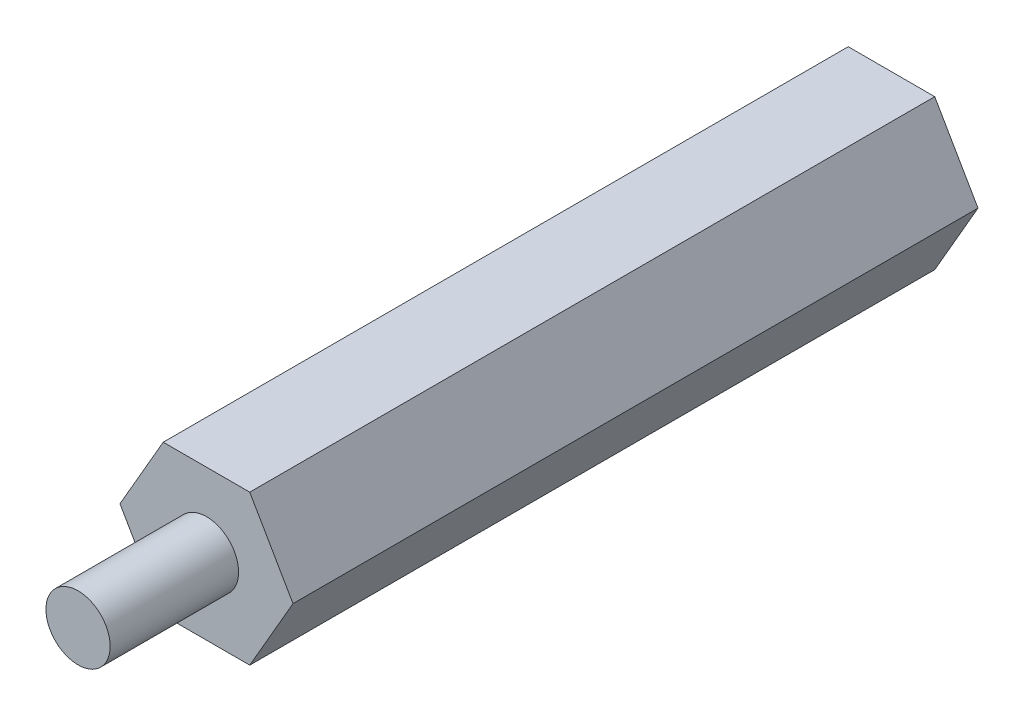
from build123d import *

# Parameters (mm, degrees)
EXTRUDE_1_DEPTH        = 32
SKETCH_2_R             = 1.5
EXTRUDE_2_DEPTH        = 6
HOLE_WIZARD_M3_1_D     = 2.5
HOLE_WIZARD_M3_1_DEPTH = 3.9
HOLE_WIZARD_M3_1_TIP   = 0.751075774


with BuildPart() as part:
    # 草图1 → 凸台-拉伸1 (new body)
    with BuildSketch(Plane.XY):
        Polygon((4.041451884, 0), (2.020725942, 3.5), (-2.020725942, 3.5), (-4.041451884, 0), (-2.020725942, -3.5), (2.020725942, -3.5), align=None)
    extrude(amount=EXTRUDE_1_DEPTH)

    # 草图2 → 凸台-拉伸2 (add)
    with BuildSketch(Plane.XY.offset(32)):
        Circle(SKETCH_2_R)
    extrude(amount=EXTRUDE_2_DEPTH)

    # M3 螺纹孔1
    with Locations(Plane(origin=(0, 0, 0), x_dir=(-1, 0, 0), z_dir=(0, 0, -1))):
        with Locations((0, 0)):
            Hole(HOLE_WIZARD_M3_1_D / 2, depth=HOLE_WIZARD_M3_1_DEPTH)
            with Locations((0, 0, -(HOLE_WIZARD_M3_1_DEPTH + HOLE_WIZARD_M3_1_TIP / 2))):  # 118° drill point
                Cone(0, HOLE_WIZARD_M3_1_D / 2, HOLE_WIZARD_M3_1_TIP, mode=Mode.SUBTRACT)


solid = part.part
